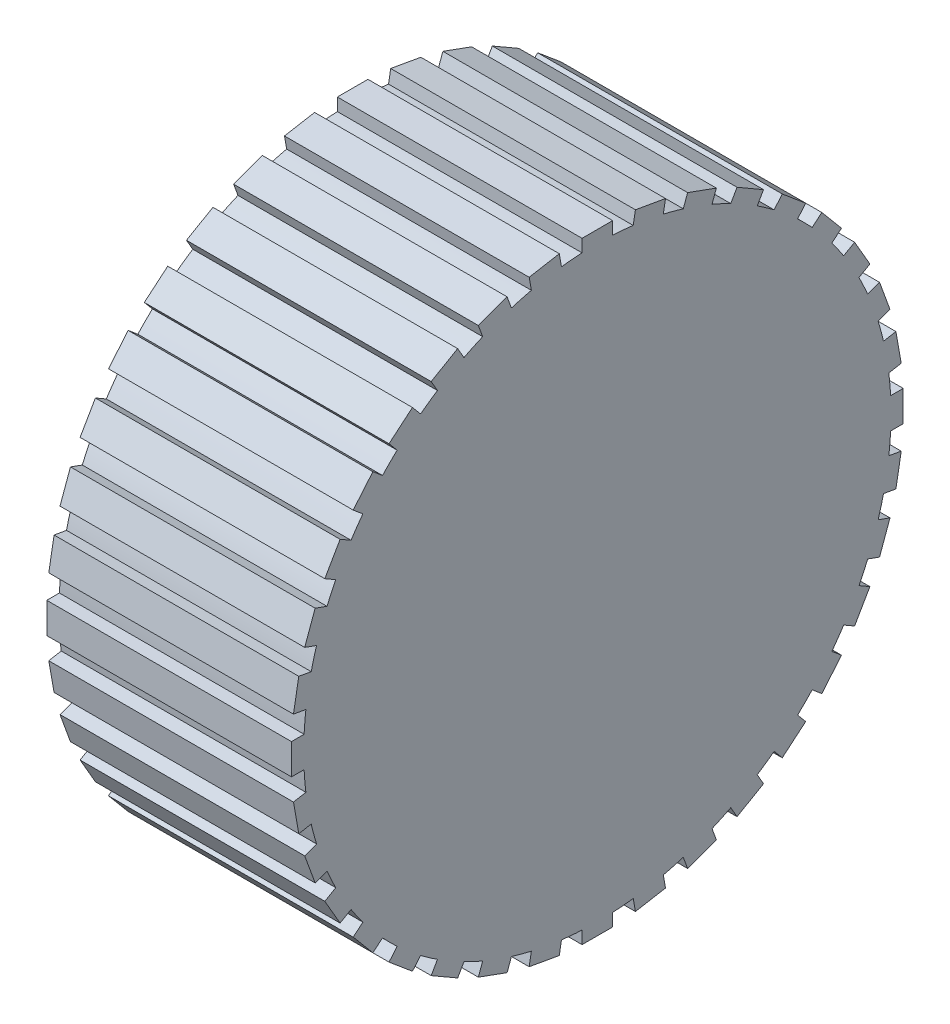
from build123d import *

# Parameters (mm, degrees)
BOSS_EXTRUDE1_DEPTH = 200
SKETCH2_R           = 50
CUT_EXTRUDE1_DEPTH  = 100


with BuildPart() as part:
    # Sketch1 → Boss-Extrude1 (new body)
    with BuildSketch(Plane(origin=(0, 0, 0), x_dir=(0, 0, -1), z_dir=(1, 0, 0))):
        with BuildLine():
            Line((-12.5, 250), (12.5, 250))
            Line((12.5, 250), (12.5, 239.674258109))
            ThreePointArc((12.5, 239.674258109), (20.917378259, 239.086727542), (29.308901242, 238.203669804))
            Line((29.308901242, 238.203669804), (31.101947504, 248.372540474))
            Line((31.101947504, 248.372540474), (55.722141329, 244.031336032))
            Line((55.722141329, 244.031336032), (53.929095067, 233.862465362))
            ThreePointArc((53.929095067, 233.862465362), (62.116570825, 231.822198309), (70.22726635, 229.495383529))
            Line((70.22726635, 229.495383529), (73.758878072, 239.198406988))
            Line((73.758878072, 239.198406988), (97.251193591, 230.647903405))
            Line((97.251193591, 230.647903405), (93.71958187, 220.944879946))
            ThreePointArc((93.71958187, 220.944879946), (101.428382818, 217.513868889), (109.011811507, 213.813996155))
            Line((109.011811507, 213.813996155), (114.174682453, 222.756350946))
            Line((114.174682453, 222.756350946), (135.825317547, 210.256350946))
            Line((135.825317547, 210.256350946), (130.662446602, 201.313996155))
            ThreePointArc((130.662446602, 201.313996155), (137.658344724, 196.596490629), (144.484087934, 191.635978704))
            Line((144.484087934, 191.635978704), (151.121346883, 199.545955901))
            Line((151.121346883, 199.545955901), (170.272457961, 183.476265659))
            Line((170.272457961, 183.476265659), (163.635199012, 175.566288462))
            ThreePointArc((163.635199012, 175.566288462), (169.705627485, 169.705627485), (175.566288462, 163.635199012))
            Line((175.566288462, 163.635199012), (183.476265659, 170.272457961))
            Line((183.476265659, 170.272457961), (199.545955901, 151.121346883))
            Line((199.545955901, 151.121346883), (191.635978704, 144.484087934))
            ThreePointArc((191.635978704, 144.484087934), (196.596490629, 137.658344724), (201.313996155, 130.662446602))
            Line((201.313996155, 130.662446602), (210.256350946, 135.825317547))
            Line((210.256350946, 135.825317547), (222.756350946, 114.174682453))
            Line((222.756350946, 114.174682453), (213.813996155, 109.011811507))
            ThreePointArc((213.813996155, 109.011811507), (217.513868889, 101.428382818), (220.944879946, 93.71958187))
            Line((220.944879946, 93.71958187), (230.647903405, 97.251193591))
            Line((230.647903405, 97.251193591), (239.198406988, 73.758878072))
            Line((239.198406988, 73.758878072), (229.495383529, 70.22726635))
            ThreePointArc((229.495383529, 70.22726635), (231.822198309, 62.116570825), (233.862465362, 53.929095067))
            Line((233.862465362, 53.929095067), (244.031336032, 55.722141329))
            Line((244.031336032, 55.722141329), (248.372540474, 31.101947504))
            Line((248.372540474, 31.101947504), (238.203669804, 29.308901242))
            ThreePointArc((238.203669804, 29.308901242), (239.086727542, 20.917378259), (239.674258109, 12.5))
            Line((239.674258109, 12.5), (250, 12.5))
            Line((250, 12.5), (250, -12.5))
            Line((250, -12.5), (239.674258109, -12.5))
            ThreePointArc((239.674258109, -12.5), (239.086727542, -20.917378259), (238.203669804, -29.308901242))
            Line((238.203669804, -29.308901242), (248.372540474, -31.101947504))
            Line((248.372540474, -31.101947504), (244.031336032, -55.722141329))
            Line((244.031336032, -55.722141329), (233.862465362, -53.929095067))
            ThreePointArc((233.862465362, -53.929095067), (231.822198309, -62.116570825), (229.495383529, -70.22726635))
            Line((229.495383529, -70.22726635), (239.198406988, -73.758878072))
            Line((239.198406988, -73.758878072), (230.647903405, -97.251193591))
            Line((230.647903405, -97.251193591), (220.944879946, -93.71958187))
            ThreePointArc((220.944879946, -93.71958187), (217.513868889, -101.428382818), (213.813996155, -109.011811507))
            Line((213.813996155, -109.011811507), (222.756350946, -114.174682453))
            Line((222.756350946, -114.174682453), (210.256350946, -135.825317547))
            Line((210.256350946, -135.825317547), (201.313996155, -130.662446602))
            ThreePointArc((201.313996155, -130.662446602), (196.596490629, -137.658344724), (191.635978704, -144.484087934))
            Line((191.635978704, -144.484087934), (199.545955901, -151.121346883))
            Line((199.545955901, -151.121346883), (183.476265659, -170.272457961))
            Line((183.476265659, -170.272457961), (175.566288462, -163.635199012))
            ThreePointArc((175.566288462, -163.635199012), (169.705627485, -169.705627485), (163.635199012, -175.566288462))
            Line((163.635199012, -175.566288462), (170.272457961, -183.476265659))
            Line((170.272457961, -183.476265659), (151.121346883, -199.545955901))
            Line((151.121346883, -199.545955901), (144.484087934, -191.635978704))
            ThreePointArc((144.484087934, -191.635978704), (137.658344724, -196.596490629), (130.662446602, -201.313996155))
            Line((130.662446602, -201.313996155), (135.825317547, -210.256350946))
            Line((135.825317547, -210.256350946), (114.174682453, -222.756350946))
            Line((114.174682453, -222.756350946), (109.011811507, -213.813996155))
            ThreePointArc((109.011811507, -213.813996155), (101.428382818, -217.513868889), (93.71958187, -220.944879946))
            Line((93.71958187, -220.944879946), (97.251193591, -230.647903405))
            Line((97.251193591, -230.647903405), (73.758878072, -239.198406988))
            Line((73.758878072, -239.198406988), (70.22726635, -229.495383529))
            ThreePointArc((70.22726635, -229.495383529), (62.116570825, -231.822198309), (53.929095067, -233.862465362))
            Line((53.929095067, -233.862465362), (55.722141329, -244.031336032))
            Line((55.722141329, -244.031336032), (31.101947504, -248.372540474))
            Line((31.101947504, -248.372540474), (29.308901242, -238.203669804))
            ThreePointArc((29.308901242, -238.203669804), (20.917378259, -239.086727542), (12.5, -239.674258109))
            Line((12.5, -239.674258109), (12.5, -250))
            Line((12.5, -250), (-12.5, -250))
            Line((-12.5, -250), (-12.5, -239.674258109))
            ThreePointArc((-12.5, -239.674258109), (-20.917378259, -239.086727542), (-29.308901242, -238.203669804))
            Line((-29.308901242, -238.203669804), (-31.101947504, -248.372540474))
            Line((-31.101947504, -248.372540474), (-55.722141329, -244.031336032))
            Line((-55.722141329, -244.031336032), (-53.929095067, -233.862465362))
            ThreePointArc((-53.929095067, -233.862465362), (-62.116570825, -231.822198309), (-70.22726635, -229.495383529))
            Line((-70.22726635, -229.495383529), (-73.758878072, -239.198406988))
            Line((-73.758878072, -239.198406988), (-97.251193591, -230.647903405))
            Line((-97.251193591, -230.647903405), (-93.71958187, -220.944879946))
            ThreePointArc((-93.71958187, -220.944879946), (-101.428382818, -217.513868889), (-109.011811507, -213.813996155))
            Line((-109.011811507, -213.813996155), (-114.174682453, -222.756350946))
            Line((-114.174682453, -222.756350946), (-135.825317547, -210.256350946))
            Line((-135.825317547, -210.256350946), (-130.662446602, -201.313996155))
            ThreePointArc((-130.662446602, -201.313996155), (-137.658344724, -196.596490629), (-144.484087934, -191.635978704))
            Line((-144.484087934, -191.635978704), (-151.121346883, -199.545955901))
            Line((-151.121346883, -199.545955901), (-170.272457961, -183.476265659))
            Line((-170.272457961, -183.476265659), (-163.635199012, -175.566288462))
            ThreePointArc((-163.635199012, -175.566288462), (-169.705627485, -169.705627485), (-175.566288462, -163.635199012))
            Line((-175.566288462, -163.635199012), (-183.476265659, -170.272457961))
            Line((-183.476265659, -170.272457961), (-199.545955901, -151.121346883))
            Line((-199.545955901, -151.121346883), (-191.635978704, -144.484087934))
            ThreePointArc((-191.635978704, -144.484087934), (-196.596490629, -137.658344724), (-201.313996155, -130.662446602))
            Line((-201.313996155, -130.662446602), (-210.256350946, -135.825317547))
            Line((-210.256350946, -135.825317547), (-222.756350946, -114.174682453))
            Line((-222.756350946, -114.174682453), (-213.813996155, -109.011811507))
            ThreePointArc((-213.813996155, -109.011811507), (-217.513868889, -101.428382818), (-220.944879946, -93.71958187))
            Line((-220.944879946, -93.71958187), (-230.647903405, -97.251193591))
            Line((-230.647903405, -97.251193591), (-239.198406988, -73.758878072))
            Line((-239.198406988, -73.758878072), (-229.495383529, -70.22726635))
            ThreePointArc((-229.495383529, -70.22726635), (-231.822198309, -62.116570825), (-233.862465362, -53.929095067))
            Line((-233.862465362, -53.929095067), (-244.031336032, -55.722141329))
            Line((-244.031336032, -55.722141329), (-248.372540474, -31.101947504))
            Line((-248.372540474, -31.101947504), (-238.203669804, -29.308901242))
            ThreePointArc((-238.203669804, -29.308901242), (-239.086727542, -20.917378259), (-239.674258109, -12.5))
            Line((-239.674258109, -12.5), (-250, -12.5))
            Line((-250, -12.5), (-250, 12.5))
            Line((-250, 12.5), (-239.674258109, 12.5))
            ThreePointArc((-239.674258109, 12.5), (-239.086727542, 20.917378259), (-238.203669804, 29.308901242))
            Line((-238.203669804, 29.308901242), (-248.372540474, 31.101947504))
            Line((-248.372540474, 31.101947504), (-244.031336032, 55.722141329))
            Line((-244.031336032, 55.722141329), (-233.862465362, 53.929095067))
            ThreePointArc((-233.862465362, 53.929095067), (-231.822198309, 62.116570825), (-229.495383529, 70.22726635))
            Line((-229.495383529, 70.22726635), (-239.198406988, 73.758878072))
            Line((-239.198406988, 73.758878072), (-230.647903405, 97.251193591))
            Line((-230.647903405, 97.251193591), (-220.944879946, 93.71958187))
            ThreePointArc((-220.944879946, 93.71958187), (-217.513868889, 101.428382818), (-213.813996155, 109.011811507))
            Line((-213.813996155, 109.011811507), (-222.756350946, 114.174682453))
            Line((-222.756350946, 114.174682453), (-210.256350946, 135.825317547))
            Line((-210.256350946, 135.825317547), (-201.313996155, 130.662446602))
            ThreePointArc((-201.313996155, 130.662446602), (-196.596490629, 137.658344724), (-191.635978704, 144.484087934))
            Line((-191.635978704, 144.484087934), (-199.545955901, 151.121346883))
            Line((-199.545955901, 151.121346883), (-183.476265659, 170.272457961))
            Line((-183.476265659, 170.272457961), (-175.566288462, 163.635199012))
            ThreePointArc((-175.566288462, 163.635199012), (-169.705627485, 169.705627485), (-163.635199012, 175.566288462))
            Line((-163.635199012, 175.566288462), (-170.272457961, 183.476265659))
            Line((-170.272457961, 183.476265659), (-151.121346883, 199.545955901))
            Line((-151.121346883, 199.545955901), (-144.484087934, 191.635978704))
            ThreePointArc((-144.484087934, 191.635978704), (-137.658344724, 196.596490629), (-130.662446602, 201.313996155))
            Line((-130.662446602, 201.313996155), (-135.825317547, 210.256350946))
            Line((-135.825317547, 210.256350946), (-114.174682453, 222.756350946))
            Line((-114.174682453, 222.756350946), (-109.011811507, 213.813996155))
            ThreePointArc((-109.011811507, 213.813996155), (-101.428382818, 217.513868889), (-93.71958187, 220.944879946))
            Line((-93.71958187, 220.944879946), (-97.251193591, 230.647903405))
            Line((-97.251193591, 230.647903405), (-73.758878072, 239.198406988))
            Line((-73.758878072, 239.198406988), (-70.22726635, 229.495383529))
            ThreePointArc((-70.22726635, 229.495383529), (-62.116570825, 231.822198309), (-53.929095067, 233.862465362))
            Line((-53.929095067, 233.862465362), (-55.722141329, 244.031336032))
            Line((-55.722141329, 244.031336032), (-31.101947504, 248.372540474))
            Line((-31.101947504, 248.372540474), (-29.308901242, 238.203669804))
            ThreePointArc((-29.308901242, 238.203669804), (-20.917378259, 239.086727542), (-12.5, 239.674258109))
            Line((-12.5, 239.674258109), (-12.5, 250))
        make_face()
    extrude(amount=BOSS_EXTRUDE1_DEPTH)

    # Sketch2 → Cut-Extrude1 (cut)
    with BuildSketch(Plane.ZY):
        Circle(SKETCH2_R)
    extrude(amount=-CUT_EXTRUDE1_DEPTH, mode=Mode.SUBTRACT)


solid = part.part
